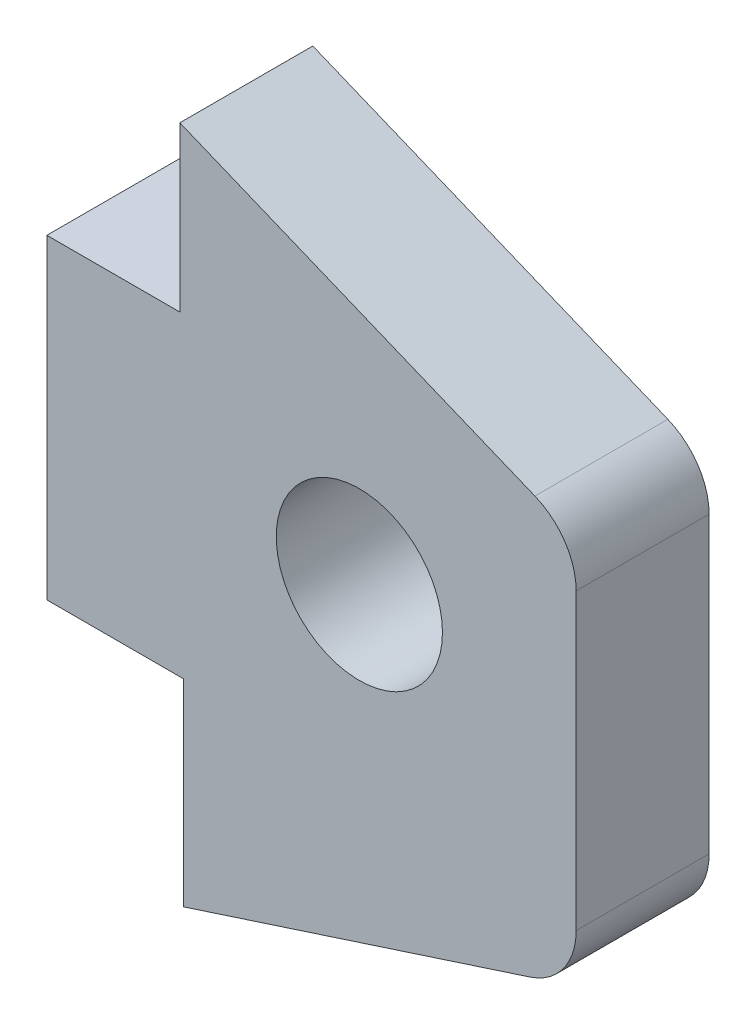
from build123d import *

# Parameters (mm, degrees)
SKETCH_1_R      = 2.5
EXTRUDE_1_DEPTH = 4
FILLET_1_R      = 2


with BuildPart() as part:
    # ｽｹｯﾁ1 → ﾎﾞｽ - 押し出し1 (new body)
    with BuildSketch(Plane.XY):
        Polygon((0, 0), (0, -9.5), (4.107330666, -9.5), (4.107330666, -15.441500508), (15.922353162, -11.607425741), (15.922353162, 0.037444009), (4, 4.930710615), (4, 0), align=None)
        with Locations((9.4, -4.4)):
            Circle(SKETCH_1_R, mode=Mode.SUBTRACT)
    extrude(amount=EXTRUDE_1_DEPTH)

    # ﾌｨﾚｯﾄ1
    fillet_1_edges = [part.edges().sort_by_distance(p)[0] for p in [
        (15.922353162, 0.037444009, 2),
        (15.922353162, -11.607425741, 2),
    ]]
    fillet(fillet_1_edges, radius=FILLET_1_R)


solid = part.part
